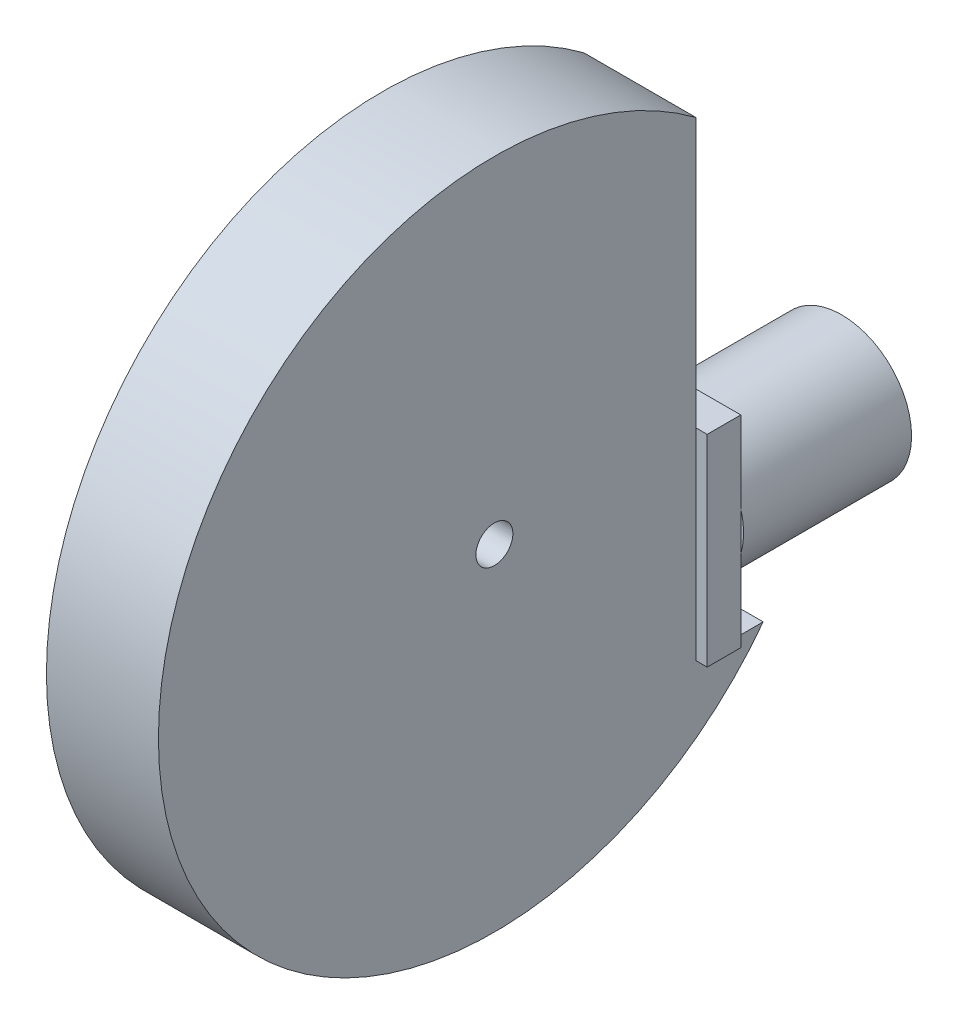
from build123d import *

# Parameters (mm, degrees)
SKETCH_2_R      = 6.25
EXTRUDE_1_DEPTH = 15
SKETCH_3_W      = 12
SKETCH_3_H      = 18
EXTRUDE_2_DEPTH = 3
SKETCH_4_R      = 1.65
EXTRUDE_3_DEPTH = 5


with BuildPart() as part:
    # ｽｹｯﾁ2 → ﾎﾞｽ - 押し出し1 (new body)
    with BuildSketch(Plane.XY):
        Circle(SKETCH_2_R)
    extrude(amount=EXTRUDE_1_DEPTH)

    # ｽｹｯﾁ3 → ﾎﾞｽ - 押し出し2 (add)
    with BuildSketch(Plane.XY.offset(15)):
        Rectangle(SKETCH_3_W, SKETCH_3_H)
    extrude(amount=EXTRUDE_2_DEPTH)

    # ｽｹｯﾁ4 → ﾎﾞｽ - 押し出し3 (add, symmetric)
    with BuildSketch(Plane(origin=(0, 0, 0), x_dir=(0, 0, -1), z_dir=(1, 0, 0))):
        with BuildLine():
            Line((-18, 9), (-18, -9))
            Line((-18, -9), (-12, -9))
            ThreePointArc((-12, -9), (-65.69848481, 4.757359313), (-18, 33))
            Line((-18, 33), (-18, 9))
        make_face()
        with Locations((-36, 9)):
            Circle(SKETCH_4_R, mode=Mode.SUBTRACT)
    extrude(amount=EXTRUDE_3_DEPTH, both=True)


solid = part.part
